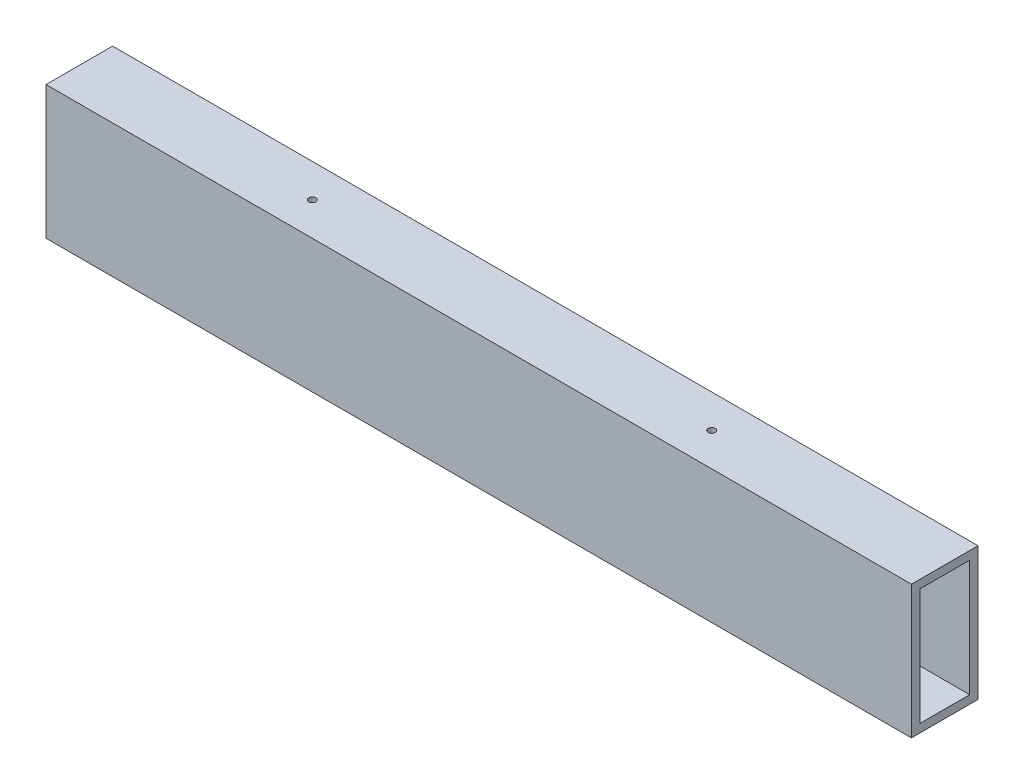
from build123d import *

# Parameters (mm, degrees)
SKETCH1_W             = 25.4
SKETCH1_H             = 50.8
SKETCH1_W_2           = 19.05
SKETCH1_H_2           = 44.45
BOSS_EXTRUDE1_DEPTH   = 330.2
F_6_32_TAPPED_HOLE6_D = 2.7051


with BuildPart() as part:
    # Sketch1 → Boss-Extrude1 (new body)
    with BuildSketch(Plane(origin=(0, 0, 0), x_dir=(0, 0, -1), z_dir=(1, 0, 0))):
        Rectangle(SKETCH1_W, SKETCH1_H)
        Rectangle(SKETCH1_W_2, SKETCH1_H_2, mode=Mode.SUBTRACT)
    extrude(amount=BOSS_EXTRUDE1_DEPTH)

    # #6-32 Tapped Hole6 (through all)
    with Locations(Plane(origin=(88.9, -25.4, 0), x_dir=(0, 0, -1), z_dir=(0, -1, 0))):
        with Locations((0, 0), (0, 152.4)):
            Hole(F_6_32_TAPPED_HOLE6_D / 2)


solid = part.part
